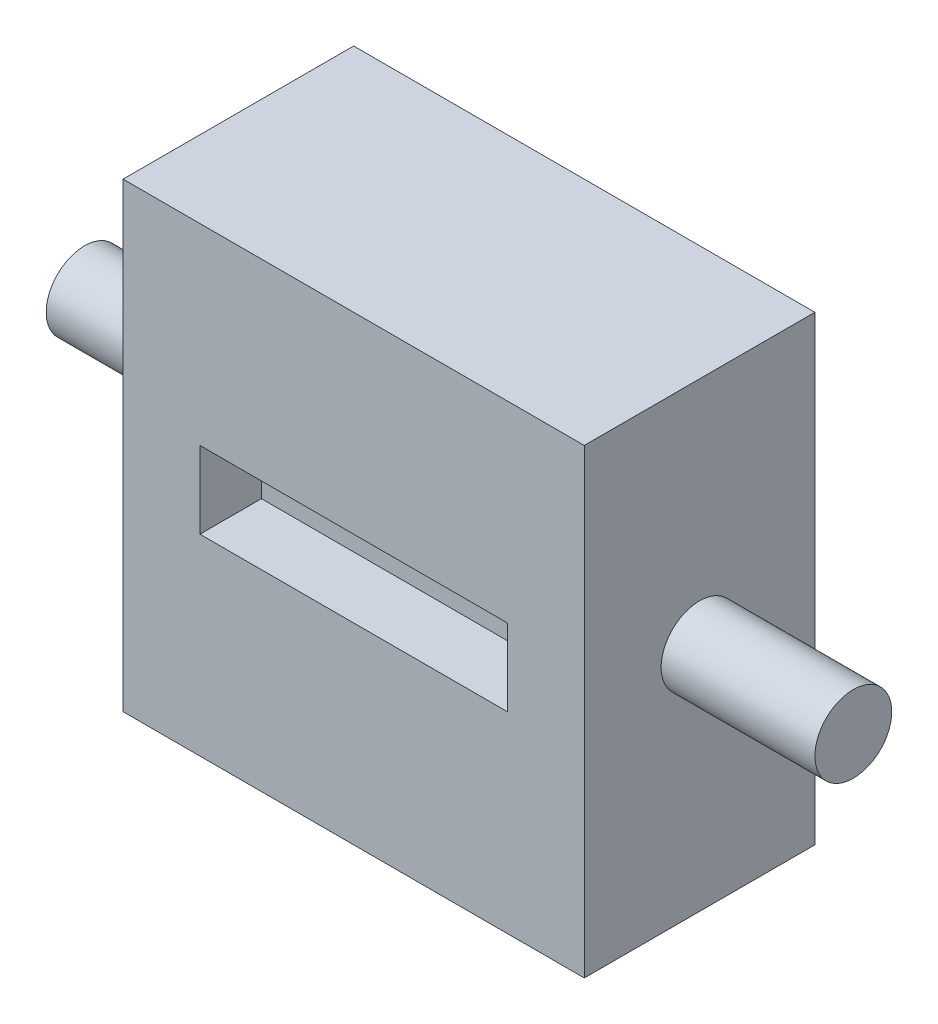
from build123d import *

# Parameters (mm, degrees)
SKETCH1_W           = 38.1
SKETCH1_H           = 38.1
BOSS_EXTRUDE1_DEPTH = 9.525
SKETCH2_W           = 25.4
SKETCH2_H           = 6.35
CUT_EXTRUDE1_DEPTH  = 5.08
CUT_EXTRUDE2_DEPTH  = 5.08
SKETCH4_R           = 3.175
BOSS_EXTRUDE2_DEPTH = 12.7


with BuildPart() as part:
    # Sketch1 → Boss-Extrude1 (new body, symmetric)
    with BuildSketch(Plane.XY):
        Rectangle(SKETCH1_W, SKETCH1_H)
    extrude(amount=BOSS_EXTRUDE1_DEPTH, both=True)

    # Sketch2 → Cut-Extrude1 (cut)
    with BuildSketch(Plane.XY.offset(9.525)):
        Rectangle(SKETCH2_W, SKETCH2_H)
    extrude(amount=-CUT_EXTRUDE1_DEPTH, mode=Mode.SUBTRACT)

    # Sketch3 → Cut-Extrude2 (cut)
    with BuildSketch(Plane(origin=(0, 0, -9.525), x_dir=(-1, 0, 0), z_dir=(0, 0, -1))):
        Polygon((3.175, 3.175), (9.525, 3.175), (9.525, -3.175), (3.175, -3.175), (3.175, -9.525), (-3.175, -9.525), (-3.175, -3.175), (-9.525, -3.175), (-9.525, 3.175), (-3.175, 3.175), (-3.175, 9.525), (3.175, 9.525), align=None)
    extrude(amount=-CUT_EXTRUDE2_DEPTH, mode=Mode.SUBTRACT)

    # Sketch4 → Boss-Extrude2 (add)
    with BuildSketch(Plane(origin=(19.05, 0, 0), x_dir=(0, 0, -1), z_dir=(1, 0, 0))):
        Circle(SKETCH4_R)
    boss_extrude2 = extrude(amount=BOSS_EXTRUDE2_DEPTH)

    # Mirror1: Boss-Extrude2 across plane
    add(boss_extrude2.mirror(Plane(origin=(0, 0, 0), x_dir=(0, 0, 1), z_dir=(1, 0, 0))))


solid = part.part
